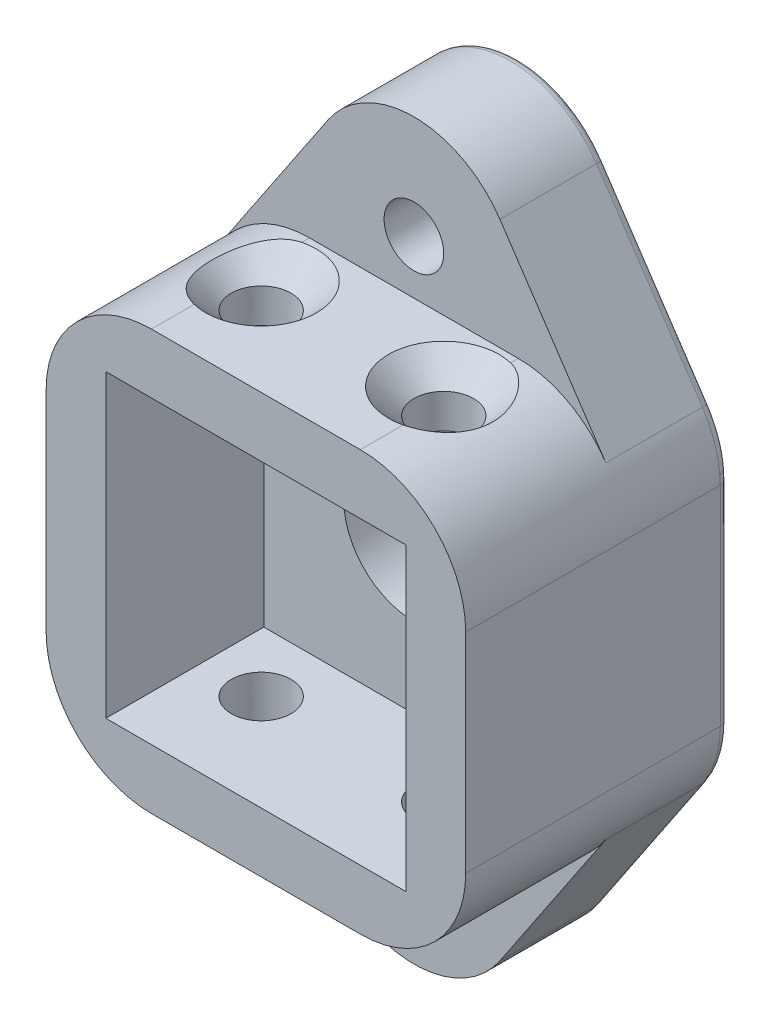
from build123d import *

# Parameters (mm, degrees)
SKETCH1_W                                           = 23.9
SKETCH1_H                                           = 23.9
SKETCH1_W_2                                         = 17.1
SKETCH1_H_2                                         = 17.1
BOSS_EXTRUDE1_DEPTH                                 = 15
FILLET1_R                                           = 6
SKETCH3_R                                           = 4
BOSS_EXTRUDE2_DEPTH                                 = 6
BOSS_EXTRUDE3_DEPTH                                 = 6
CBORE_FOR_M3_HEX_SOCKET_HEAD_CAP_SCREW1_D           = 3.4
CBORE_FOR_M3_HEX_SOCKET_HEAD_CAP_SCREW1_CBORE_D     = 6.5
CBORE_FOR_M3_HEX_SOCKET_HEAD_CAP_SCREW1_CBORE_DEPTH = 3.4
FILLET2_R                                           = 0.5
CSK_FOR_M3_COUNTERSUNK_FLAT_HEAD_SCREW1_D           = 3.4
CSK_FOR_M3_COUNTERSUNK_FLAT_HEAD_SCREW1_CSINK_D     = 6.3
CSK_FOR_M3_COUNTERSUNK_FLAT_HEAD_SCREW1_CSINK_ANGLE = 90


with BuildPart() as part:
    # Sketch1 → Boss-Extrude1 (new body)
    with BuildSketch(Plane.XY):
        Rectangle(SKETCH1_W, SKETCH1_H)
        Rectangle(SKETCH1_W_2, SKETCH1_H_2, mode=Mode.SUBTRACT)
    extrude(amount=BOSS_EXTRUDE1_DEPTH)

    # Fillet1
    fillet1_edges = [part.edges().sort_by_distance(p)[0] for p in [
        (11.95, -11.95, 7.5),
        (-11.95, -11.95, 7.5),
        (-11.95, 11.95, 7.5),
        (11.95, 11.95, 7.5),
    ]]
    fillet(fillet1_edges, radius=FILLET1_R)

    # Sketch3 → Boss-Extrude2 (add)
    with BuildSketch(Plane(origin=(0, 0, 0), x_dir=(-1, 0, 0), z_dir=(0, 0, -1))):
        with BuildLine():
            Line((-5.95, -11.95), (5.95, -11.95))
            ThreePointArc((5.95, -11.95), (10.192640687, -10.192640687), (11.95, -5.95))
            Line((11.95, -5.95), (11.95, 5.95))
            ThreePointArc((11.95, 5.95), (10.192640687, 10.192640687), (5.95, 11.95))
            Line((5.95, 11.95), (-5.95, 11.95))
            ThreePointArc((-5.95, 11.95), (-10.192640687, 10.192640687), (-11.95, 5.95))
            Line((-11.95, 5.95), (-11.95, -5.95))
            ThreePointArc((-11.95, -5.95), (-10.192640687, -10.192640687), (-5.95, -11.95))
        make_face()
        Circle(SKETCH3_R, mode=Mode.SUBTRACT)
    extrude(amount=-BOSS_EXTRUDE2_DEPTH)

    # Sketch2 → Boss-Extrude3 (add)
    with BuildSketch(Plane(origin=(0, 0, 0), x_dir=(-1, 0, 0), z_dir=(0, 0, -1))):
        with BuildLine():
            Line((-5.95, 11.95), (5.95, 11.95))
            ThreePointArc((5.95, 11.95), (8.773656269, 11.244049988), (10.932859145, 9.292321759))
            Line((10.932859145, 9.292321759), (4.899811493, 18.286616396))
            ThreePointArc((4.899811493, 18.286616396), (0, 20.9), (-4.899811493, 18.286616396))
            Line((-4.899811493, 18.286616396), (-10.932859145, 9.292321759))
            ThreePointArc((-10.932859145, 9.292321759), (-8.773656269, 11.244049988), (-5.95, 11.95))
        make_face()
        with BuildLine():
            Line((4.899811493, -18.286616396), (10.932859145, -9.292321759))
            ThreePointArc((10.932859145, -9.292321759), (8.773656269, -11.244049988), (5.95, -11.95))
            Line((5.95, -11.95), (-5.95, -11.95))
            ThreePointArc((-5.95, -11.95), (-8.773656269, -11.244049988), (-10.932859145, -9.292321759))
            Line((-10.932859145, -9.292321759), (-4.899811493, -18.286616396))
            ThreePointArc((-4.899811493, -18.286616396), (0, -20.9), (4.899811493, -18.286616396))
        make_face()
    extrude(amount=-BOSS_EXTRUDE3_DEPTH)

    # CBORE for M3 Hex Socket Head Cap Screw1 (through all)
    with Locations(Plane(origin=(0, 0, 0), x_dir=(-1, 0, 0), z_dir=(0, 0, -1))):
        with Locations((0, 15), (0, -15)):
            CounterBoreHole(CBORE_FOR_M3_HEX_SOCKET_HEAD_CAP_SCREW1_D / 2, CBORE_FOR_M3_HEX_SOCKET_HEAD_CAP_SCREW1_CBORE_D / 2, CBORE_FOR_M3_HEX_SOCKET_HEAD_CAP_SCREW1_CBORE_DEPTH)

    # Fillet2
    fillet2_edges = [part.edges().sort_by_distance(p)[0] for p in [
        (-11.690085142, -7.696832151, 0),
        (0, -20.9, 0),
        (7.916335319, -13.789469077, 0),
        (-7.916335319, -13.789469077, 0),
        (11.95, 0, 0),
        (-11.95, 0, 0),
        (-11.690085142, 7.696832151, 0),
        (11.690085142, -7.696832151, 0),
        (11.690085142, 7.696832151, 0),
        (-7.916335319, 13.789469077, 0),
        (0, 20.9, 0),
        (7.916335319, 13.789469077, 0),
    ]]
    fillet(fillet2_edges, radius=FILLET2_R)

    # CSK for M3 Countersunk Flat Head Screw1 (through all)
    with Locations(Plane(origin=(0, 11.95, 0), x_dir=(1, 0, 0), z_dir=(0, 1, 0))):
        with Locations((-5.2, -9.5), (5.2, -9.5)):
            CounterSinkHole(CSK_FOR_M3_COUNTERSUNK_FLAT_HEAD_SCREW1_D / 2, CSK_FOR_M3_COUNTERSUNK_FLAT_HEAD_SCREW1_CSINK_D / 2, counter_sink_angle=CSK_FOR_M3_COUNTERSUNK_FLAT_HEAD_SCREW1_CSINK_ANGLE)


solid = part.part
